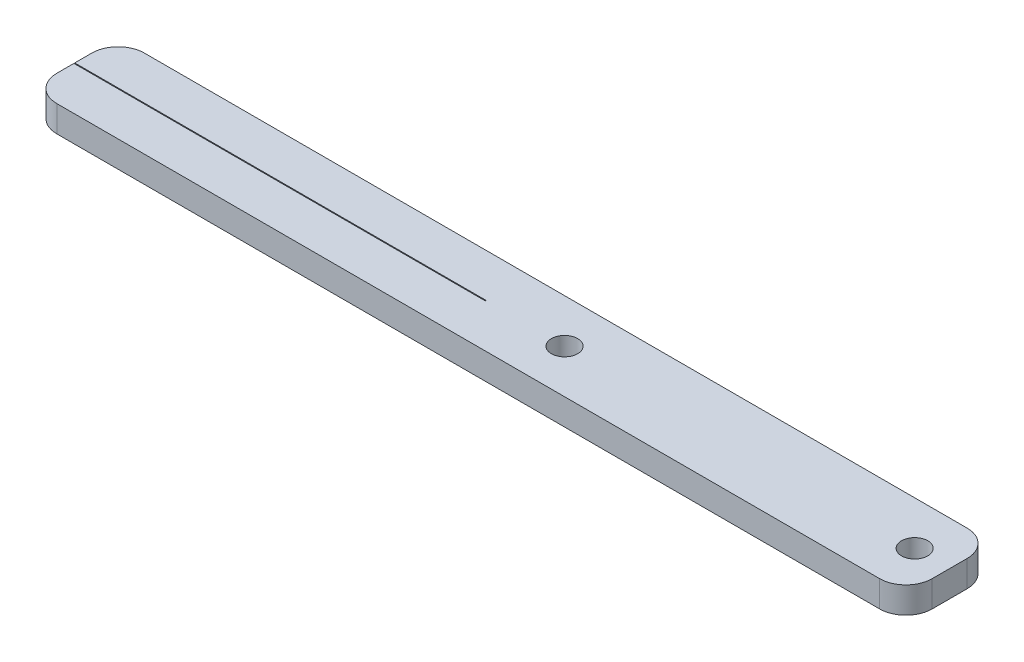
from build123d import *

# Parameters (mm, degrees)
SKETCH1_W             = 100
SKETCH1_H             = 10
BOSS_EXTRUDE1_DEPTH   = 3
FILLET1_R             = 3
F_3_0MM_DOWEL_HOLE1_D = 3
SKETCH2_W             = 47
SKETCH2_H             = 0.1
CUT_EXTRUDE1_DEPTH    = 10


with BuildPart() as part:
    # Sketch1 → Boss-Extrude1 (new body)
    with BuildSketch(Plane(origin=(0, 0, 0), x_dir=(1, 0, 0), z_dir=(0, 1, 0))):
        Rectangle(SKETCH1_W, SKETCH1_H)
    extrude(amount=BOSS_EXTRUDE1_DEPTH)

    # Fillet1
    fillet1_edges = [part.edges().sort_by_distance(p)[0] for p in [
        (50, 1.5, 5),
        (-50, 1.5, 5),
        (-50, 1.5, -5),
        (50, 1.5, -5),
    ]]
    fillet(fillet1_edges, radius=FILLET1_R)

    # Ø3.0mm Dowel Hole1 (through all)
    with Locations(Plane(origin=(0, 3, 0), x_dir=(1, 0, 0), z_dir=(0, 1, 0))):
        with Locations((46, 0), (6, 0)):
            Hole(F_3_0MM_DOWEL_HOLE1_D / 2)

    # Sketch2 → Cut-Extrude1 (cut)
    with BuildSketch(Plane(origin=(0, 3, 0), x_dir=(1, 0, 0), z_dir=(0, 1, 0))):
        with Locations((-26.5, 0)):
            Rectangle(SKETCH2_W, SKETCH2_H)
    extrude(amount=-CUT_EXTRUDE1_DEPTH, mode=Mode.SUBTRACT)


solid = part.part
